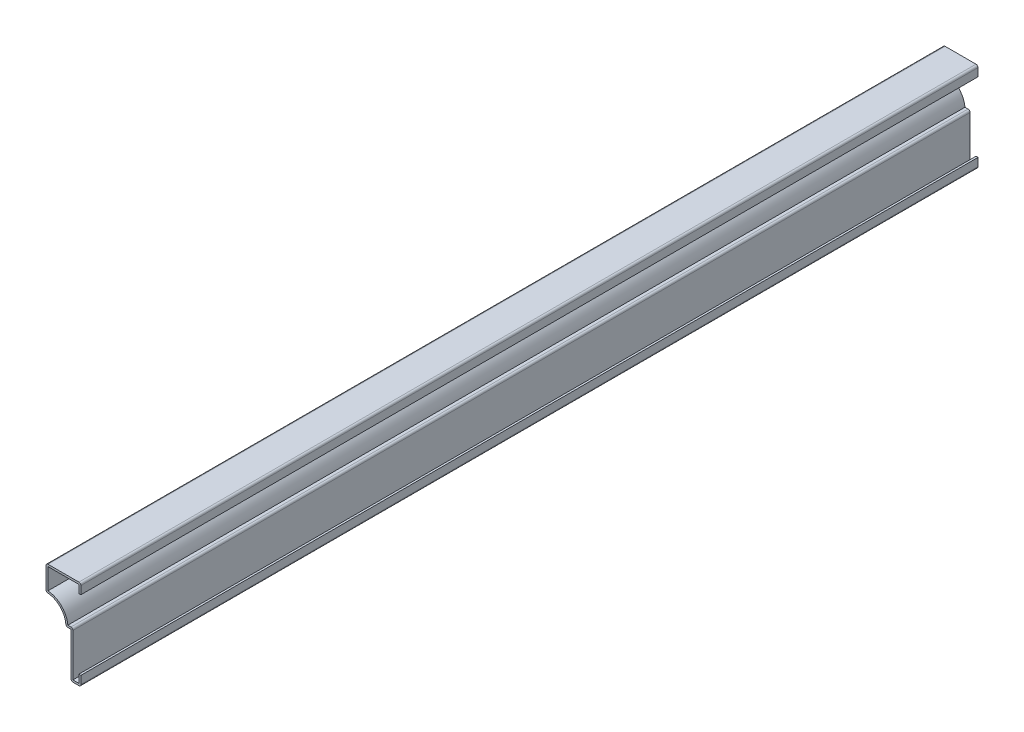
from build123d import *

# Parameters (mm, degrees)
EXTRUDE_THIN1_DEPTH = 571.5
FILLET1_R           = 1.27


with BuildPart() as part:
    # Sketch1 → Extrude-Thin1 (new body)
    with BuildSketch(Plane.XY):
        with BuildLine():
            Line((0, 6.35), (0, 0))
            Line((0, 0), (-6.35, 0))
            Line((-6.35, 0), (-6.35, 28.575))
            Line((-6.35, 28.575), (-9.525, 28.575))
            ThreePointArc((-9.525, 28.575), (-13.244743879, 37.555256121), (-22.225, 41.275))
            Line((-22.225, 41.275), (-22.225, 57.15))
            Line((-22.225, 57.15), (0, 57.15))
            Line((0, 57.15), (0, 50.8))
            Line((0, 50.8), (-1.27, 50.8))
            Line((-1.27, 50.8), (-1.27, 55.88))
            Line((-1.27, 55.88), (-20.955, 55.88))
            Line((-20.955, 55.88), (-20.955, 42.487152961))
            ThreePointArc((-20.955, 42.487152961), (-12.346718267, 38.453281733), (-8.312847039, 29.845))
            Line((-8.312847039, 29.845), (-5.08, 29.845))
            Line((-5.08, 29.845), (-5.08, 1.27))
            Line((-5.08, 1.27), (-1.27, 1.27))
            Line((-1.27, 1.27), (-1.27, 6.35))
            Line((-1.27, 6.35), (0, 6.35))
        make_face()
    extrude(amount=-EXTRUDE_THIN1_DEPTH)

    # Fillet1
    fillet1_edges = [part.edges().sort_by_distance(p)[0] for p in [
        (-5.08, 29.845, -285.75),
        (0, 0, -285.75),
        (-6.35, 0, -285.75),
        (-9.525, 28.575, -285.75),
        (-22.225, 41.275, -285.75),
        (-22.225, 57.15, -285.75),
        (0, 57.15, -285.75),
    ]]
    fillet(fillet1_edges, radius=FILLET1_R)


solid = part.part
